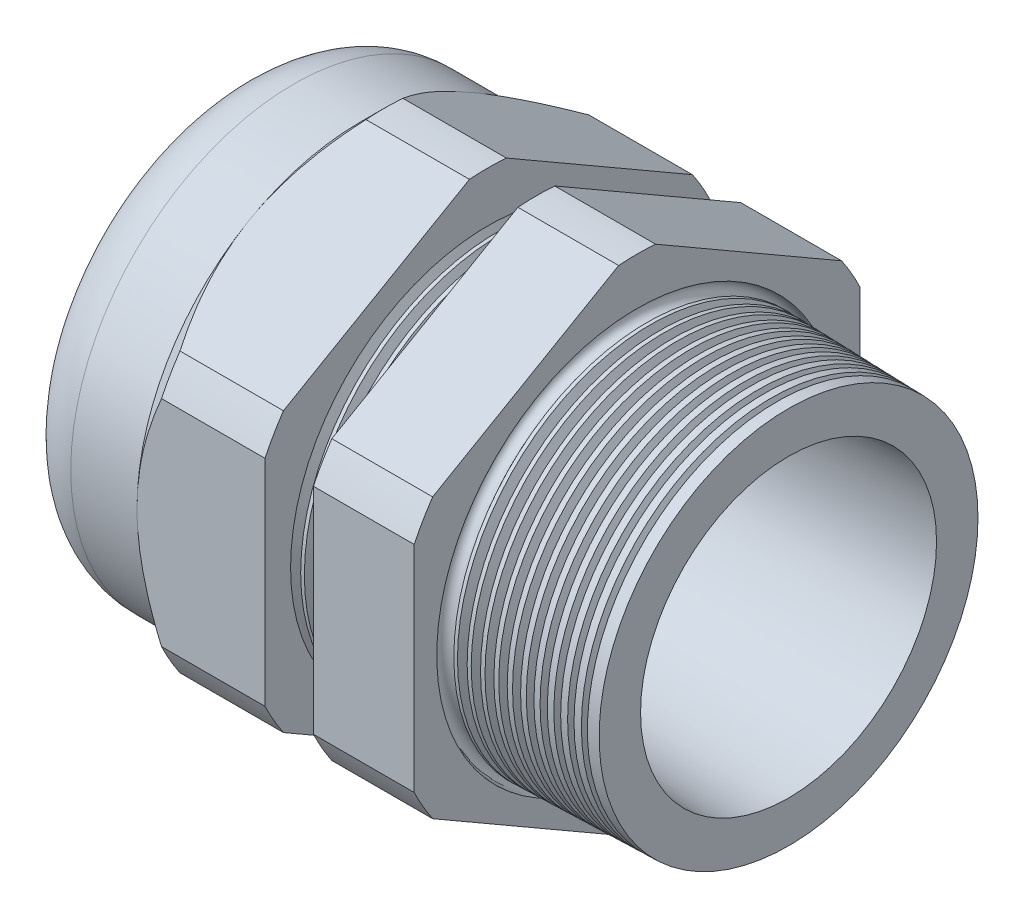
from build123d import *

# Parameters (mm, degrees)
LPATTERN6_COUNT    = 4
LPATTERN6_PITCH    = 1.5748
LPATTERN7_COUNT    = 11
LPATTERN7_PITCH    = 1.5748
SKETCH12_OUTSIDE_W = 140.978
SKETCH12_OUTSIDE_H = 140.978
CUT_EXTRUDE2_DEPTH = 52.04003
FILLET4_R          = 7.112
SKETCH19_OUTSIDE_W = 83.724
SKETCH19_OUTSIDE_H = 89.564
SKETCH19_OUTSIDE_R = 26.543
CUT_EXTRUDE3_DEPTH = 3.99796
CUT_EXTRUDE3_DRAFT = -45
SKETCH28_R         = 0.9525


with BuildPart() as part:
    # Sketch10 → Revolve2 (revolve)
    with BuildSketch(Plane.XY, mode=Mode.PRIVATE) as revolve2_sk:
        Polygon((-40.88003, 16.002), (-25.64003, 16.002), (10.16, 17.62125), (10.16, 22.557543222), (-7.874, 23.029780132), (-7.874, 53.086), (-19.873976, 53.086), (-19.873976, 23.344010562), (-25.64003, 23.495), (-25.64003, 53.086), (-40.88003, 53.086), (-40.88003, 26.543), (-55.88, 26.543), (-55.88, 17.62125), (-40.88003, 17.62125), align=None)
    revolve(revolve2_sk.sketch.rotate(Axis((0, 0, 0), (-1, 0, 0)), 90), axis=Axis((0, 0, 0), (-1, 0, 0)))  # turned: the seam where the file's is

    # Sketch26 → Cut-Revolve1 (revolve, cut)
    with BuildSketch(Plane.XY, mode=Mode.PRIVATE) as cut_revolve1_sk:
        Polygon((-25.64003, 23.495), (-24.467256271, 23.464289839), (-25.080238915, 22.463993077), align=None)
    cut_revolve1 = revolve(cut_revolve1_sk.sketch.rotate(Axis((0, 0, 0), (-1, 0, 0)), 90), axis=Axis((0, 0, 0), (-1, 0, 0)), mode=Mode.SUBTRACT)  # turned: the seam where the file's is

    # LPattern6: Cut-Revolve1 ×4
    with Locations(*[(i * LPATTERN6_PITCH, 0, 0) for i in range(1, LPATTERN6_COUNT)]):
        add(cut_revolve1, mode=Mode.SUBTRACT)

    # Sketch27 → Cut-Revolve2 (revolve, cut)
    with BuildSketch(Plane.XY, mode=Mode.PRIVATE) as cut_revolve2_sk:
        Polygon((-7.874, 23.029780132), (-6.701226271, 22.999069971), (-7.314208915, 21.998773209), align=None)
    cut_revolve2 = revolve(cut_revolve2_sk.sketch.rotate(Axis((0, 0, 0), (-1, 0, 0)), 90), axis=Axis((0, 0, 0), (-1, 0, 0)), mode=Mode.SUBTRACT)  # turned: the seam where the file's is

    # LPattern7: Cut-Revolve2 ×11
    with Locations(*[(i * LPATTERN7_PITCH, 0, 0) for i in range(1, LPATTERN7_COUNT)]):
        add(cut_revolve2, mode=Mode.SUBTRACT)

    # Sketch12 outside → Cut-Extrude2 (cut, through all)
    with BuildSketch(Plane.ZY.offset(40.88003)):
        Rectangle(SKETCH12_OUTSIDE_W, SKETCH12_OUTSIDE_H)
        with BuildLine():
            Line((-2.19715092, 29.380690715), (-24.34584908, 16.59313387))
            ThreePointArc((-24.34584908, 16.59313387), (-25.515472645, 14.731365), (-26.543, 12.787556845))
            Line((-26.543, 12.787556845), (-26.543, -12.787556845))
            ThreePointArc((-26.543, -12.787556845), (-25.515472645, -14.731365), (-24.34584908, -16.59313387))
            Line((-24.34584908, -16.59313387), (-2.19715092, -29.380690715))
            ThreePointArc((-2.19715092, -29.380690715), (0, -29.46273), (2.19715092, -29.380690715))
            Line((2.19715092, -29.380690715), (24.34584908, -16.59313387))
            ThreePointArc((24.34584908, -16.59313387), (25.515472645, -14.731365), (26.543, -12.787556845))
            Line((26.543, -12.787556845), (26.543, 12.787556845))
            ThreePointArc((26.543, 12.787556845), (25.515472645, 14.731365), (24.34584908, 16.59313387))
            Line((24.34584908, 16.59313387), (2.19715092, 29.380690715))
            ThreePointArc((2.19715092, 29.380690715), (0, 29.46273), (-2.19715092, 29.380690715))
        make_face(mode=Mode.SUBTRACT)
    extrude(amount=-CUT_EXTRUDE2_DEPTH, mode=Mode.SUBTRACT)

    # Fillet4
    fillet4_edges = [part.edges().sort_by_distance(p)[0] for p in [
        (-55.88, 0, 26.543),
    ]]
    fillet(fillet4_edges, radius=FILLET4_R)


with BuildPart() as body_2:
    # Sketch23 → Revolve6 (revolve)
    with BuildSketch(Plane.XY, mode=Mode.PRIVATE) as revolve6_sk:
        with BuildLine():
            Line((-54.8894, 17.62125), (-40.88003, 17.62125))
            Line((-40.88003, 17.62125), (-40.88003, 16.002))
            Line((-40.88003, 16.002), (-55.118, 16.002))
            Line((-55.118, 16.002), (-55.118, 17.39265))
            ThreePointArc((-55.118, 17.39265), (-55.05104461, 17.55429461), (-54.8894, 17.62125))
        make_face()
    revolve(revolve6_sk.sketch.rotate(Axis((0, 0, 0), (-1, 0, 0)), 270), axis=Axis((0, 0, 0), (-1, 0, 0)))  # turned: the seam where the file's is


with BuildPart() as cut_extrude3_tool:
    # Sketch19 outside → Cut-Extrude3 (with draft: the straight prism first)
    with BuildSketch(Plane.ZY.offset(40.88003)):
        Rectangle(SKETCH19_OUTSIDE_W, SKETCH19_OUTSIDE_H)
        Circle(SKETCH19_OUTSIDE_R, mode=Mode.SUBTRACT)
    extrude(amount=-CUT_EXTRUDE3_DEPTH)
    # Cut-Extrude3: the draft: its side faces are tilted about the plane it starts from
    cut_extrude3_sides = [cut_extrude3_tool.faces().sort_by_distance(p)[0] for p in [
        (-38.88105, -44.782, 0),
        (-38.88105, 0, 41.862),
        (-38.88105, 44.782, 0),
        (-38.88105, 0, -41.862),
        (-38.88105, 0, -26.543),
    ]]
    draft(cut_extrude3_sides, Plane.ZY.offset(40.88003), CUT_EXTRUDE3_DRAFT)


with BuildPart() as part_1:
    add(part.part)

    # Cut-Extrude3: cut by cut_extrude3_tool
    add(cut_extrude3_tool.part, mode=Mode.SUBTRACT)

    # Sketch28 → Cut-Revolve3 (revolve, cut)
    with BuildSketch(Plane.XY, mode=Mode.PRIVATE) as cut_revolve3_sk:
        with Locations((-7.8486, -22.902780132)):
            Circle(SKETCH28_R)
    revolve(cut_revolve3_sk.sketch.rotate(Axis((10.16, 0, 0), (-1, 0, 0)), 90), axis=Axis((10.16, 0, 0), (-1, 0, 0)), mode=Mode.SUBTRACT)  # turned: the seam where the file's is


solid = Compound([body_2.part, part_1.part])
